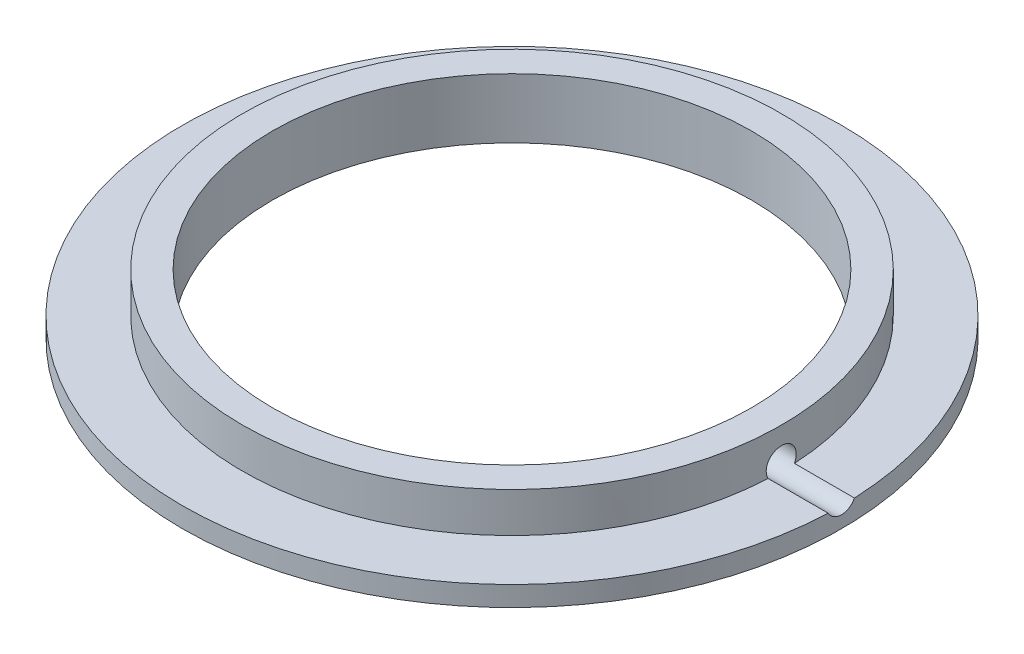
from build123d import *

# Parameters (mm, degrees)
SKETCH1_R           = 16.5
BOSS_EXTRUDE1_DEPTH = 1
SKETCH2_R           = 13.5
BOSS_EXTRUDE2_DEPTH = 3
SKETCH3_R           = 12
CUT_EXTRUDE1_DEPTH  = 3
SKETCH5_R           = 0.75
CUT_EXTRUDE3_DEPTH  = 17


with BuildPart() as part:
    # Sketch1 → Boss-Extrude1 (new body)
    with BuildSketch(Plane(origin=(0, 0, 0), x_dir=(1, 0, 0), z_dir=(0, 1, 0))):
        Circle(SKETCH1_R)
    extrude(amount=BOSS_EXTRUDE1_DEPTH)

    # Sketch2 → Boss-Extrude2 (add)
    with BuildSketch(Plane(origin=(0, 0, 0), x_dir=(1, 0, 0), z_dir=(0, 1, 0))):
        Circle(SKETCH2_R)
    extrude(amount=BOSS_EXTRUDE2_DEPTH)

    # Sketch3 → Cut-Extrude1 (cut)
    with BuildSketch(Plane(origin=(0, 0, 0), x_dir=(1, 0, 0), z_dir=(0, 1, 0))):
        Circle(SKETCH3_R)
    extrude(amount=CUT_EXTRUDE1_DEPTH, mode=Mode.SUBTRACT)

    # Sketch5 → Cut-Extrude3 (cut)
    with BuildSketch(Plane(origin=(0, 0, 0), x_dir=(0, 0, -1), z_dir=(1, 0, 0))):
        with Locations((0, 1.36)):
            Circle(SKETCH5_R)
    extrude(amount=CUT_EXTRUDE3_DEPTH, mode=Mode.SUBTRACT)


solid = part.part
